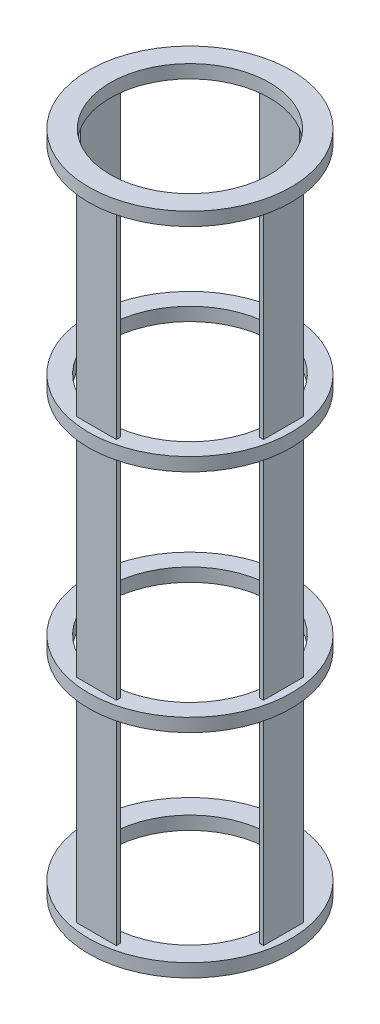
from build123d import *

# Parameters (mm, degrees)
ESQUISSE1_R                  = 76.2
ESQUISSE1_R_2                = 60
BOSS_EXTRU_1_DEPTH           = 10
ESQUISSE2_W                  = 30
ESQUISSE2_H                  = 3
BOSS_EXTRU_2_DEPTH           = 480
R_P_TITION_CIRCULAIRE1_COUNT = 4
R_P_TITION_LIN_AIRE1_COUNT   = 2
R_P_TITION_LIN_AIRE1_PITCH   = 490
ESQUISSE5_R                  = 76.2
ESQUISSE5_R_2                = 62.5
BOSS_EXTRU_3_DEPTH           = 10
R_P_TITION_LIN_AIRE2_COUNT   = 2
R_P_TITION_LIN_AIRE2_PITCH   = 170


with BuildPart() as part:
    # Esquisse1 → Boss.-Extru.1 (new body)
    with BuildSketch(Plane(origin=(0, 0, 0), x_dir=(1, 0, 0), z_dir=(0, 1, 0))):
        Circle(ESQUISSE1_R)
        Circle(ESQUISSE1_R_2, mode=Mode.SUBTRACT)
    boss_extru_1 = extrude(amount=BOSS_EXTRU_1_DEPTH)

    # Esquisse2 → Boss.-Extru.2 (add)
    with BuildSketch(Plane(origin=(0, 10, 0), x_dir=(1, 0, 0), z_dir=(0, 1, 0))):
        with Locations((0, 68.920167566)):
            Rectangle(ESQUISSE2_W, ESQUISSE2_H)
    boss_extru_2 = extrude(amount=BOSS_EXTRU_2_DEPTH)

    # Répétition circulaire1: Boss.-Extru.2 ×4 about axis
    r_p_tition_circulaire1_axis = Axis((0, 0, 0), (0, 1, 0))
    for i in range(1, R_P_TITION_CIRCULAIRE1_COUNT):
        add(boss_extru_2.rotate(r_p_tition_circulaire1_axis, i * 360 / R_P_TITION_CIRCULAIRE1_COUNT))

    # Répétition linéaire1: Boss.-Extru.1 ×2
    with Locations(*[(0, i * R_P_TITION_LIN_AIRE1_PITCH, 0) for i in range(1, R_P_TITION_LIN_AIRE1_COUNT)]):
        add(boss_extru_1)

    # Esquisse5 → Boss.-Extru.3 (add)
    with BuildSketch(Plane(origin=(0, 160, 0), x_dir=(1, 0, 0), z_dir=(0, 1, 0))):
        Circle(ESQUISSE5_R)
        Circle(ESQUISSE5_R_2, mode=Mode.SUBTRACT)
    boss_extru_3 = extrude(amount=BOSS_EXTRU_3_DEPTH)

    # Répétition linéaire2: Boss.-Extru.3 ×2
    with Locations(*[(0, i * R_P_TITION_LIN_AIRE2_PITCH, 0) for i in range(1, R_P_TITION_LIN_AIRE2_COUNT)]):
        add(boss_extru_3)


solid = part.part
